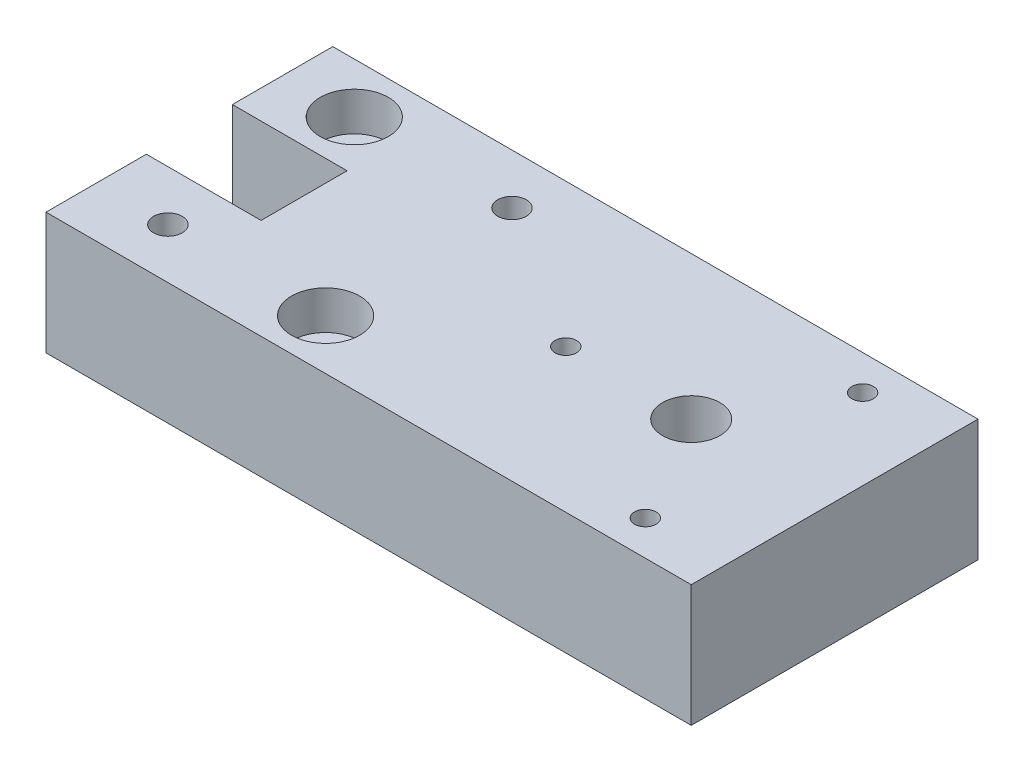
from build123d import *

# Parameters (mm, degrees)
EXTRUDE_1_DEPTH        = 17
SKETCH_4_R             = 2.75
SKETCH_4_R_2           = 2
SKETCH_4_R_3           = 4
SKETCH_4_R_4           = 1.5
CUT_EXTRUDE_2_DEPTH    = 18
SKETCH_5_R             = 4.75
CUT_EXTRUDE_3_DEPTH    = 5.4
HOLE_WIZARD_M4_1_D     = 6
HOLE_WIZARD_M4_1_DEPTH = 4
HOLE_WIZARD_M4_1_TIP   = 1.802581857


with BuildPart() as part:
    # 스케치1 → 보스-돌출1 (new body)
    with BuildSketch(Plane(origin=(0, 0, 0), x_dir=(1, 0, 0), z_dir=(0, 1, 0))):
        Polygon((-90, -6), (-90, -20), (0, -20), (0, 20), (-90, 20), (-90, 6), (-74, 6), (-74, -6), align=None)
    extrude(amount=EXTRUDE_1_DEPTH)

    # 스케치4 → 컷-돌출2 (cut, through all)
    with BuildSketch(Plane.XZ):
        with Locations((-80, -13)):
            Circle(SKETCH_4_R)
        with Locations((-80, 13)):
            Circle(SKETCH_4_R_2)
        with Locations((-58, 13)):
            Circle(SKETCH_4_R)
        with Locations((-58, -13)):
            Circle(SKETCH_4_R_2)
        with Locations((-20, 0)):
            Circle(SKETCH_4_R_3)
        with Locations((-11.25, 15.155444566)):
            Circle(SKETCH_4_R_4)
        with Locations((-11.25, -15.155444566)):
            Circle(SKETCH_4_R_4)
        with Locations((-37.5, 0)):
            Circle(SKETCH_4_R_4)
    extrude(amount=-CUT_EXTRUDE_2_DEPTH, mode=Mode.SUBTRACT)

    # 스케치5 → 컷-돌출3 (cut)
    with BuildSketch(Plane(origin=(0, 17, 0), x_dir=(1, 0, 0), z_dir=(0, 1, 0))):
        with Locations((-80, 13)):
            Circle(SKETCH_5_R)
        with Locations((-58, -13)):
            Circle(SKETCH_5_R)
    extrude(amount=-CUT_EXTRUDE_3_DEPTH, mode=Mode.SUBTRACT)

    # M4 여유 구멍1
    with Locations(Plane.ZY.offset(74)):
        with Locations((0, 12)):
            Hole(HOLE_WIZARD_M4_1_D / 2, depth=HOLE_WIZARD_M4_1_DEPTH)
            with Locations((0, 0, -(HOLE_WIZARD_M4_1_DEPTH + HOLE_WIZARD_M4_1_TIP / 2))):  # 118° drill point
                Cone(0, HOLE_WIZARD_M4_1_D / 2, HOLE_WIZARD_M4_1_TIP, mode=Mode.SUBTRACT)


solid = part.part
